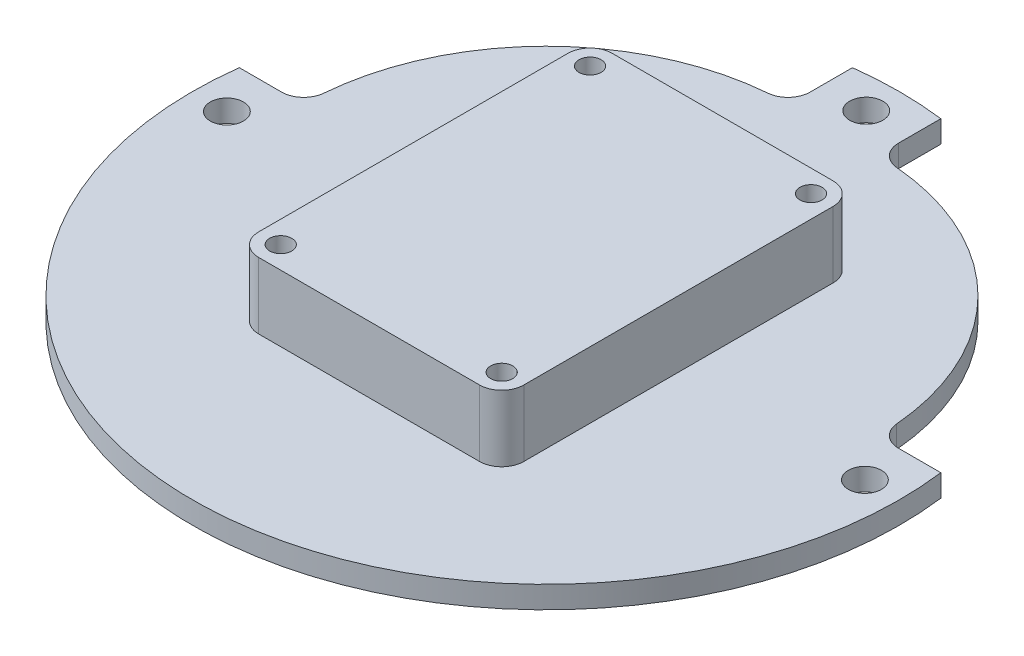
from build123d import *

# Parameters (mm, degrees)
SKETCH1_R           = 3.175
BOSS_EXTRUDE1_DEPTH = 25.4
SKETCH1_3_R         = 4.7625
BOSS_EXTRUDE2_DEPTH = 6.35


with BuildPart() as part:
    # Sketch1 → Boss-Extrude1 (new body)
    with BuildSketch(Plane(origin=(0, 0, 0), x_dir=(1, 0, 0), z_dir=(0, 1, 0))):
        with BuildLine():
            ThreePointArc((-38.1, -44.45), (-36.240128061, -48.940128061), (-31.75, -50.8))
            Line((-31.75, -50.8), (31.75, -50.8))
            ThreePointArc((31.75, -50.8), (36.240128061, -48.940128061), (38.1, -44.45))
            Line((38.1, -44.45), (38.1, 44.45))
            ThreePointArc((38.1, 44.45), (36.240128061, 48.940128061), (31.75, 50.8))
            Line((31.75, 50.8), (-31.75, 50.8))
            ThreePointArc((-31.75, 50.8), (-36.240128061, 48.940128061), (-38.1, 44.45))
            Line((-38.1, 44.45), (-38.1, -44.45))
        make_face()
        with Locations((-31.75, -44.45)):
            Circle(SKETCH1_R, mode=Mode.SUBTRACT)
        with Locations((31.75, -44.45)):
            Circle(SKETCH1_R, mode=Mode.SUBTRACT)
        with Locations((-31.75, 44.45)):
            Circle(SKETCH1_R, mode=Mode.SUBTRACT)
        with Locations((31.75, 44.45)):
            Circle(SKETCH1_R, mode=Mode.SUBTRACT)
    extrude(amount=BOSS_EXTRUDE1_DEPTH)

    # Sketch1_3 → Boss-Extrude2 (add)
    with BuildSketch(Plane(origin=(0, 0, 0), x_dir=(1, 0, 0), z_dir=(0, 1, 0))):
        with BuildLine():
            ThreePointArc((12.7, 100.803124952), (0, 101.6), (-12.7, 100.803124952))
            Line((-12.7, 100.803124952), (-12.7, 88.634955719))
            ThreePointArc((-12.7, 88.634955719), (-14.376526542, 84.335985396), (-18.520833333, 82.307042742))
            ThreePointArc((-18.520833333, 82.307042742), (-62.091408666, 62.091408666), (-82.307042742, 18.520833333))
            ThreePointArc((-82.307042742, 18.520833333), (-84.335985396, 14.376526542), (-88.634955719, 12.7))
            Line((-88.634955719, 12.7), (-100.803124952, 12.7))
            ThreePointArc((-100.803124952, 12.7), (0, -101.6), (100.803124952, 12.7))
            Line((100.803124952, 12.7), (88.634955719, 12.7))
            ThreePointArc((88.634955719, 12.7), (84.335985396, 14.376526542), (82.307042742, 18.520833333))
            ThreePointArc((82.307042742, 18.520833333), (62.091408666, 62.091408666), (18.520833333, 82.307042742))
            ThreePointArc((18.520833333, 82.307042742), (14.376526542, 84.335985396), (12.7, 88.634955719))
            Line((12.7, 88.634955719), (12.7, 100.803124952))
        make_face()
        with Locations((-91.676562476, 0)):
            Circle(SKETCH1_3_R, mode=Mode.SUBTRACT)
        with BuildLine():
            Line((31.75, -50.8), (-31.75, -50.8))
            ThreePointArc((-31.75, -50.8), (-36.240128061, -48.940128061), (-38.1, -44.45))
            Line((-38.1, -44.45), (-38.1, 44.45))
            ThreePointArc((-38.1, 44.45), (-36.240128061, 48.940128061), (-31.75, 50.8))
            Line((-31.75, 50.8), (31.75, 50.8))
            ThreePointArc((31.75, 50.8), (36.240128061, 48.940128061), (38.1, 44.45))
            Line((38.1, 44.45), (38.1, -44.45))
            ThreePointArc((38.1, -44.45), (36.240128061, -48.940128061), (31.75, -50.8))
        make_face(mode=Mode.SUBTRACT)
        with Locations((0, 92.075)):
            Circle(SKETCH1_3_R, mode=Mode.SUBTRACT)
        with Locations((91.676562476, 0)):
            Circle(SKETCH1_3_R, mode=Mode.SUBTRACT)
    extrude(amount=BOSS_EXTRUDE2_DEPTH)


solid = part.part
